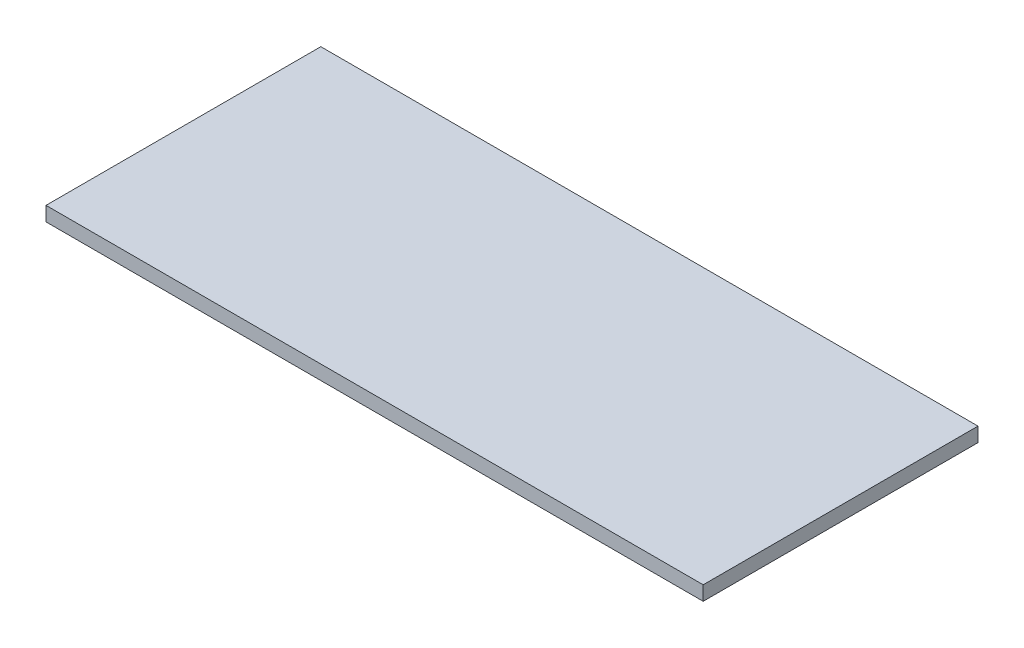
from build123d import *

# Parameters (mm, degrees)
SKETCH1_W           = 873.125
SKETCH1_H           = 365.125
BOSS_EXTRUDE1_DEPTH = 19.05


with BuildPart() as part:
    # Sketch1 → Boss-Extrude1 (new body)
    with BuildSketch(Plane(origin=(0, 0, 0), x_dir=(1, 0, 0), z_dir=(0, 1, 0))):
        Rectangle(SKETCH1_W, SKETCH1_H)
    extrude(amount=BOSS_EXTRUDE1_DEPTH)


solid = part.part
